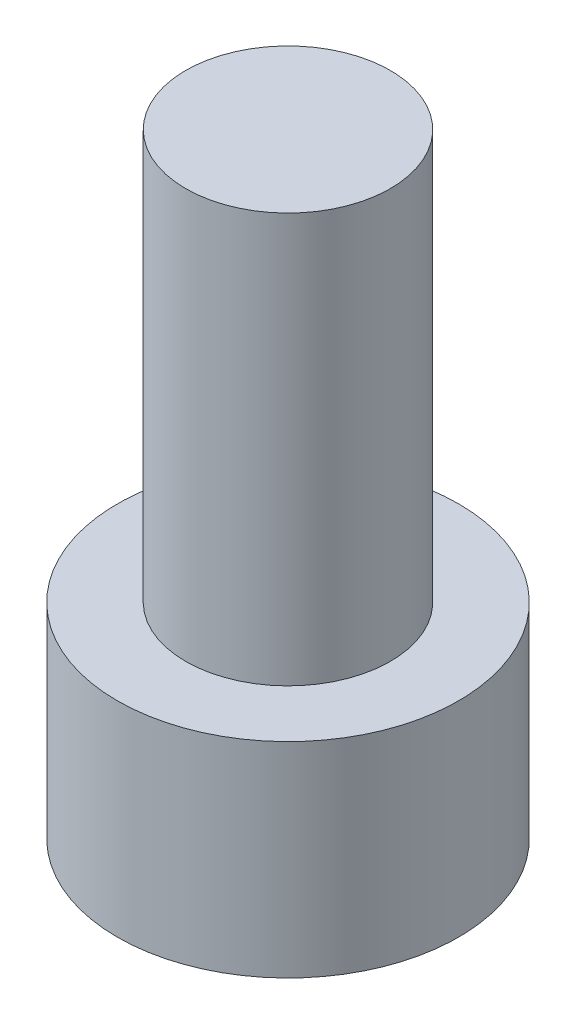
from build123d import *

# Parameters (mm, degrees)
SKETCH1_R           = 2.5
BOSS_EXTRUDE1_DEPTH = 3
SKETCH1_3_R         = 1.5
BOSS_EXTRUDE2_DEPTH = 9


with BuildPart() as part:
    # Sketch1 → Boss-Extrude1 (new body)
    with BuildSketch(Plane(origin=(0, 0, 0), x_dir=(1, 0, 0), z_dir=(0, 1, 0))):
        Circle(SKETCH1_R)
    extrude(amount=BOSS_EXTRUDE1_DEPTH)

    # Sketch1_3 → Boss-Extrude2 (add)
    with BuildSketch(Plane(origin=(0, 0, 0), x_dir=(1, 0, 0), z_dir=(0, 1, 0))):
        Circle(SKETCH1_3_R)
    extrude(amount=BOSS_EXTRUDE2_DEPTH)


solid = part.part
